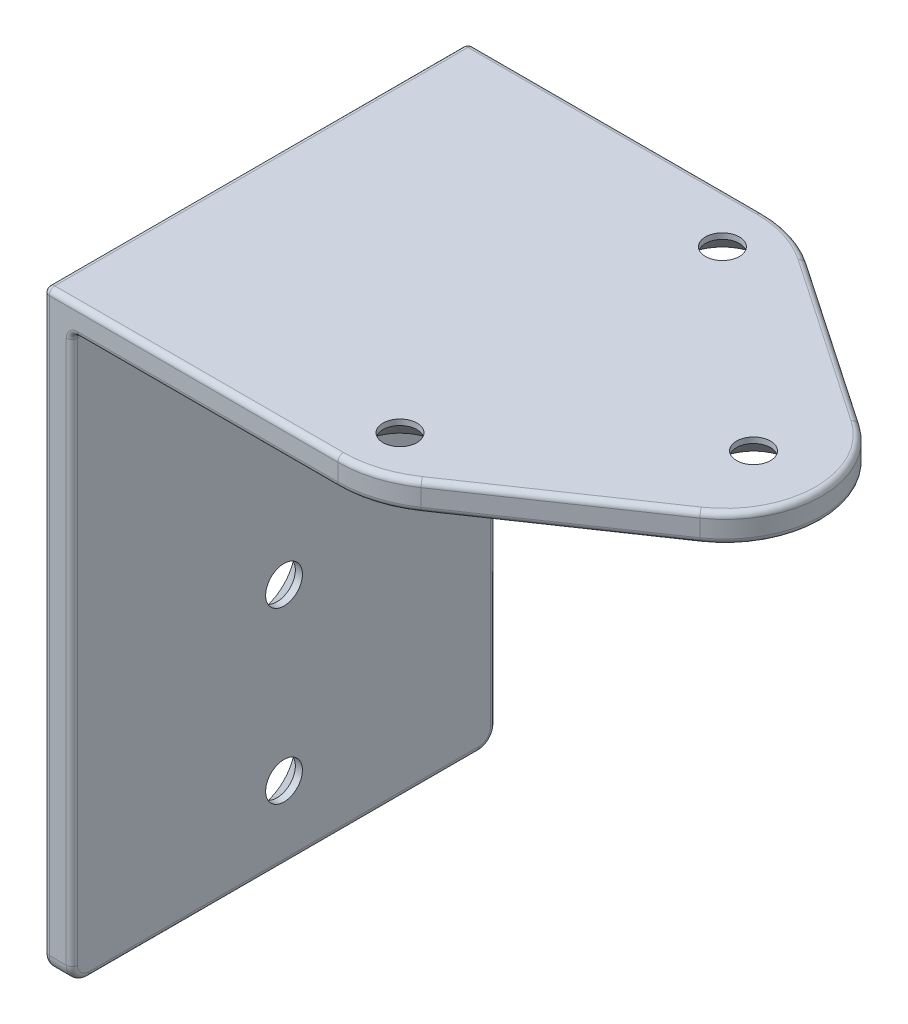
from build123d import *

# Parameters (mm, degrees)
BOSS_EXTRU_1_DEPTH         = 37.5
CONG_1_R                   = 1
CONG_2_R                   = 1
ENL_V_MAT_EXTRU_1_DEPTH    = 106
CONG_3_R                   = 3
CONG_4_R                   = 3
R_P_TITION_LIN_AIRE2_COUNT = 3
R_P_TITION_LIN_AIRE2_PITCH = 30
CONG_5_R                   = 1


with BuildPart() as part:
    # Esquisse1 → Boss.-Extru.1 (new body, symmetric)
    with BuildSketch(Plane.XY):
        Polygon((50, 0), (50, 5), (-50, 5), (-50, -100), (-45, -100), (-45, 0), align=None)
    extrude(amount=BOSS_EXTRU_1_DEPTH, both=True)

    # Congé1
    cong_1_edges = [part.edges().sort_by_distance(p)[0] for p in [
        (-50, 5, 0),
    ]]
    fillet(cong_1_edges, radius=CONG_1_R)

    # Congé2
    cong_2_edges = [part.edges().sort_by_distance(p)[0] for p in [
        (-45, 0, 0),
    ]]
    fillet(cong_2_edges, radius=CONG_2_R)

    # Esquisse2 → Enlèv. mat.-Extru.1 (cut, through all)
    with BuildSketch(Plane(origin=(0, 5, 0), x_dir=(1, 0, 0), z_dir=(0, 1, 0))):
        with BuildLine():
            Line((13.264657274, 34.025964314), (42.574958683, 14.047069667))
            ThreePointArc((42.574958683, 14.047069667), (50, 0), (42.574958683, -14.047069667))
            Line((42.574958683, -14.047069667), (13.264657274, -34.025964314))
            ThreePointArc((13.264657274, -34.025964314), (7.894095084, -36.611767138), (2, -37.5))
            Line((2, -37.5), (2, -49.357406445))
            Line((2, -49.357406445), (93.230488108, -49.357406445))
            Line((93.230488108, -49.357406445), (93.230488108, 49.357406445))
            Line((93.230488108, 49.357406445), (2, 49.357406445))
            Line((2, 49.357406445), (2, 37.5))
            ThreePointArc((2, 37.5), (7.894095084, 36.611767138), (13.264657274, 34.025964314))
        make_face()
    extrude(amount=-ENL_V_MAT_EXTRU_1_DEPTH, mode=Mode.SUBTRACT)

    # Congé3
    cong_3_edges = [part.edges().sort_by_distance(p)[0] for p in [
        (-47.5, -100, -37.5),
    ]]
    fillet(cong_3_edges, radius=CONG_3_R)

    # Congé4
    cong_4_edges = [part.edges().sort_by_distance(p)[0] for p in [
        (-47.5, -100, 37.5),
    ]]
    fillet(cong_4_edges, radius=CONG_4_R)

    # Esquisse5 → Enlèvement de matière-Révolution2 (revolve, cut)
    with BuildSketch(Plane.XY, mode=Mode.PRIVATE) as enl_vement_de_mati_re_r_volution2_sk:
        Polygon((-44, -87), (-44, -83.75), (-46.25, -83.75), (-50, -80), (-50, -87), align=None)
    enl_vement_de_mati_re_r_volution2 = revolve(enl_vement_de_mati_re_r_volution2_sk.sketch.rotate(Axis((-72.134969263, -87, 0), (1, 0, 0)), 90), axis=Axis((-72.134969263, -87, 0), (1, 0, 0)), mode=Mode.SUBTRACT)  # turned: the seam where the file's is

    # Répétition linéaire2: Enlèvement de matière-Révolution2 ×3
    with Locations(*[(0, i * R_P_TITION_LIN_AIRE2_PITCH, 0) for i in range(1, R_P_TITION_LIN_AIRE2_COUNT)]):
        add(enl_vement_de_mati_re_r_volution2, mode=Mode.SUBTRACT)

    # Congé5
    cong_5_edges = [part.edges().sort_by_distance(p)[0] for p in [
        (-50, -46.5, -37.5),
        (-50, -46.5, 37.5),
        (-49.707106781, 4.707106781, -37.5),
        (-49.707106781, 4.707106781, 37.5),
        (-21, 0, -37.5),
        (-21, 0, 37.5),
        (-44.707106781, -0.292893219, 37.5),
        (-44.707106781, -0.292893219, -37.5),
        (-23.5, 5, -37.5),
        (-23.5, 5, 37.5),
        (27.919807978, 0, 24.03651699),
        (50, 0, 0),
        (27.919807978, 0, -24.03651699),
        (7.894095084, 0, 36.611767138),
        (7.894095084, 0, -36.611767138),
        (50, 5, 0),
        (7.894095084, 5, -36.611767138),
        (27.919807978, 5, -24.03651699),
        (27.919807978, 5, 24.03651699),
        (7.894095084, 5, 36.611767138),
        (-45, -49, -37.5),
        (-45, -99.121320344, -36.621320344),
        (-50, -99.121320344, -36.621320344),
        (-45, -49, 37.5),
        (-50, -100, 0),
        (-45, -100, 0),
        (-50, -99.121320344, 36.621320344),
        (-45, -99.121320344, 36.621320344),
    ]]
    fillet(cong_5_edges, radius=CONG_5_R)

    # Esquisse6 → Enlèvement de matière-Révolution3 (revolve, cut)
    with BuildSketch(Plane.XY):
        Polygon((38, 6), (35, 6), (35, 4), (30, -1), (38, -1), align=None)
    revolve(axis=Axis((38, 8.257594869, 0), (0, -1, 0)), mode=Mode.SUBTRACT)

    # Esquisse10 → Enlèvement de matière-Révolution5 (revolve, cut)
    with BuildSketch(Plane.XY.offset(28.5)):
        Polygon((4, 6), (1, 6), (1, 4), (-4, -1), (4, -1), align=None)
    enl_vement_de_mati_re_r_volution5 = revolve(axis=Axis((4, 7.732158055, 28.5), (0, -1, 0)), mode=Mode.SUBTRACT)

    # Symétrie1: Enlèvement de matière-Révolution5 across plane
    add(enl_vement_de_mati_re_r_volution5.mirror(Plane.XY), mode=Mode.SUBTRACT)


solid = part.part
